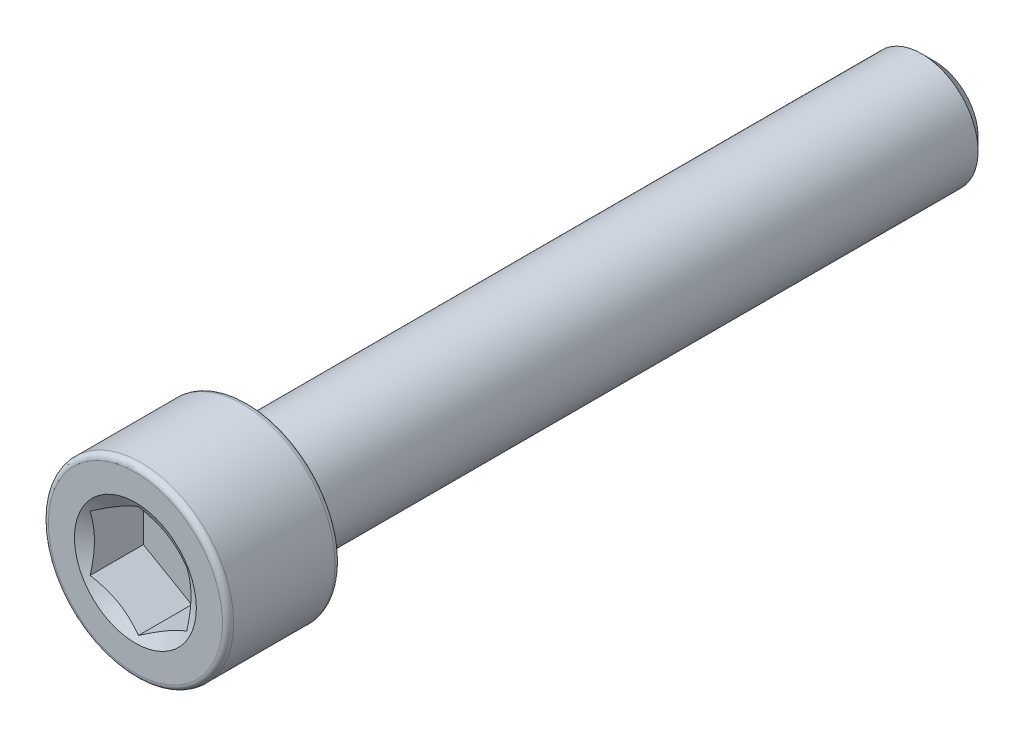
from build123d import *

# Parameters (mm, degrees)
CUT_EXTRUDE1_START = 14.7828
CUT_EXTRUDE1_DEPTH = 2.0828


with BuildPart() as part:
    # Sketch2 → Revolve1 (revolve)
    with BuildSketch(Plane(origin=(0, 0, 0), x_dir=(0, 0, -1), z_dir=(1, 0, 0)), mode=Mode.PRIVATE) as revolve1_sk:
        with BuildLine():
            Line((14.7828, 0), (14.7828, 1.60655))
            Line((14.7828, 1.60655), (14.30655, 2.0828))
            Line((14.30655, 2.0828), (-10.6172, 2.0828))
            Line((-10.6172, 2.0828), (-10.6172, 3.22072))
            ThreePointArc((-10.6172, 3.22072), (-10.6782038, 3.3679962), (-10.82548, 3.429))
            Line((-10.82548, 3.429), (-14.57452, 3.429))
            ThreePointArc((-14.57452, 3.429), (-14.7217962, 3.3679962), (-14.7828, 3.22072))
            Line((-14.7828, 3.22072), (-14.7828, 0))
            Line((-14.7828, 0), (14.7828, 0))
        make_face()
    revolve(revolve1_sk.sketch.rotate(Axis((0, 0, -14.7828), (0, 0, 1)), 90), axis=Axis((0, 0, -14.7828), (0, 0, 1)))

    # Sketch3 → Cut-Extrude1 (cut)
    with BuildSketch(Plane.XY.offset(CUT_EXTRUDE1_START)):
        Polygon((-1.7859375, 1.031111496), (-1.7859375, -1.031111496), (0, -2.062222993), (1.7859375, -1.031111496), (1.7859375, 1.031111496), (0, 2.062222993), align=None)
    extrude(amount=-CUT_EXTRUDE1_DEPTH, mode=Mode.SUBTRACT)

    # Cut-Extrude2 cone 1 section (through the dimple's axis) → Cut-Extrude2 (revolve, cut)
    with BuildSketch(Plane(origin=(0, 0, 14.7828), x_dir=(0, -1, 0), z_dir=(1, 0, 0))):
        Polygon((0, 0), (2.255305827, 0), (0, 1.302101426), align=None)
    revolve(axis=Axis((0, 0, 14.7828), (0, 0, -1)), mode=Mode.SUBTRACT)


solid = part.part
